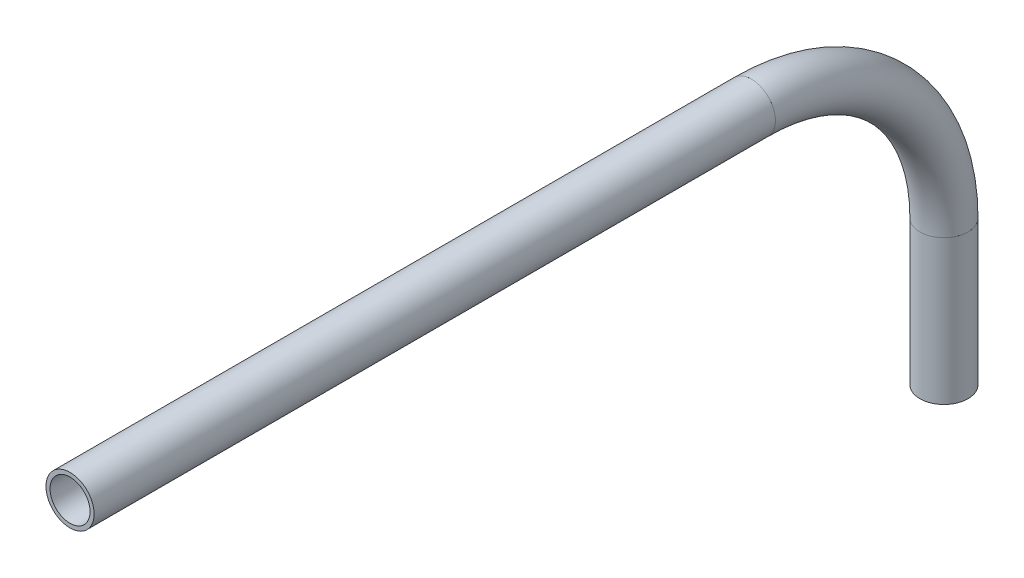
from build123d import *

# Parameters (mm, degrees)
SKETCH11_ON_SEGMENT_1_R   = 6.35
SKETCH11_ON_SEGMENT_1_R_2 = 5.2832
PIPE_0_5_SCH_40_1_DEPTH   = 179.679470862
SKETCH11_ON_SEGMENT_2_R   = 6.35
SKETCH11_ON_SEGMENT_2_R_2 = 5.2832
PIPE_0_5_SCH_40_1_2_ANGLE = 90
SKETCH11_R                = 6.35
SKETCH11_R_2              = 5.2832
PIPE_0_5_SCH_40_1_3_DEPTH = 38.1


with BuildPart() as part:
    # Sketch11 on segment 1 (carried to segment 1) → Pipe 0.5 SCH 40(1) (new body)
    with BuildSketch(Plane(origin=(0, -232.817799036, 129.639190881), x_dir=(0, -1, 0), z_dir=(0, 0, 1))):
        Circle(SKETCH11_ON_SEGMENT_1_R)
        Circle(SKETCH11_ON_SEGMENT_1_R_2, mode=Mode.SUBTRACT)
    extrude(amount=PIPE_0_5_SCH_40_1_DEPTH)


with BuildPart() as body_2:
    # Sketch11 on segment 2 (carried to the start of arc 2) → Pipe 0.5 SCH 40_1 2 (revolve)
    with BuildSketch(Plane(origin=(0, -232.817799036, 129.639190881), x_dir=(0, 1, 0), z_dir=(0, 0, -1))):
        Circle(SKETCH11_ON_SEGMENT_2_R)
        Circle(SKETCH11_ON_SEGMENT_2_R_2, mode=Mode.SUBTRACT)
    revolve(axis=Axis((0, -283.617799036, 129.639190881), (-1, 0, 0)), revolution_arc=PIPE_0_5_SCH_40_1_2_ANGLE)


with BuildPart() as body_3:
    # Sketch11 → Pipe 0.5 SCH 40_1 3 (new body)
    with BuildSketch(Plane(origin=(0, -283.617799036, 78.839190881), x_dir=(0, 0, -1), z_dir=(0, -1, 0))):
        Circle(SKETCH11_R)
        Circle(SKETCH11_R_2, mode=Mode.SUBTRACT)
    extrude(amount=PIPE_0_5_SCH_40_1_3_DEPTH)


solid = Compound([part.part, body_2.part, body_3.part])
